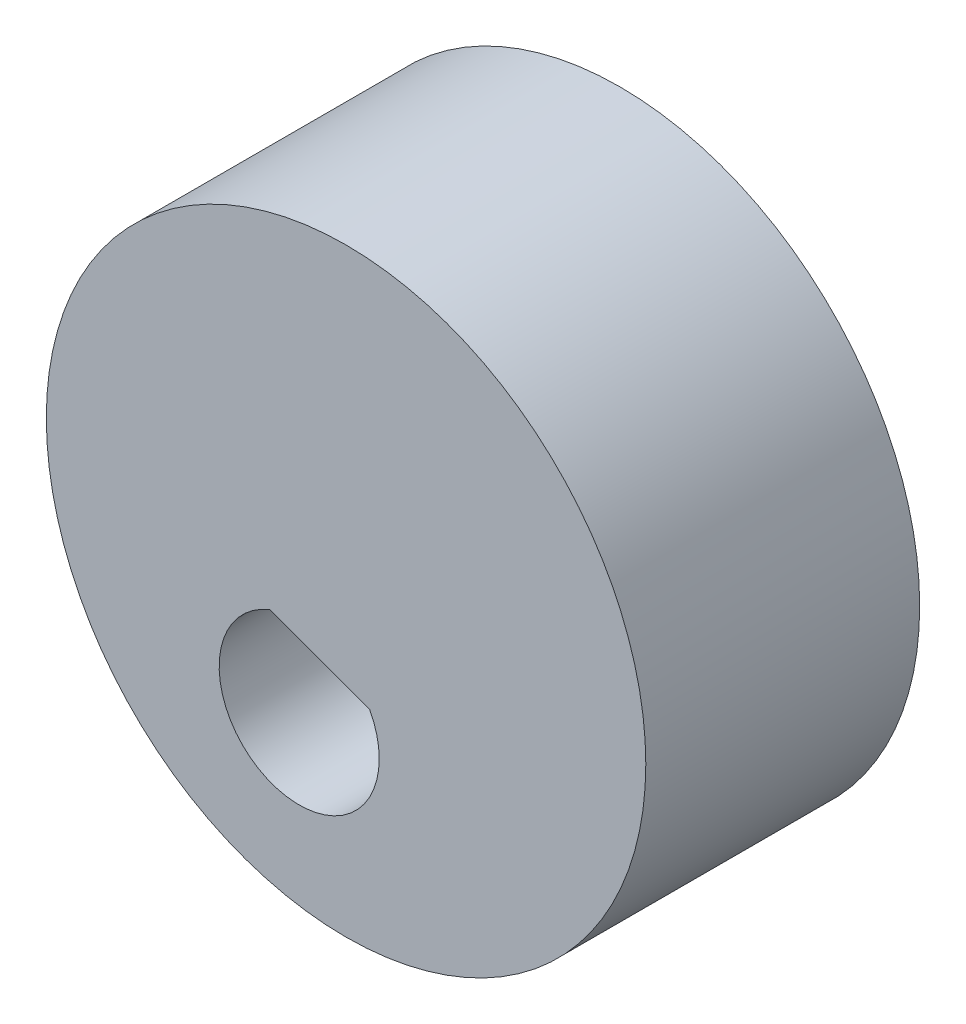
from build123d import *

# Parameters (mm, degrees)
SKETCH2_R           = 9.85
BOSS_EXTRUDE1_DEPTH = 9


with BuildPart() as part:
    # Sketch2 → Boss-Extrude1 (new body)
    with BuildSketch(Plane.XY.offset(-65.766846416)):
        with Locations((-18.602199674, -32.896108502)):
            Circle(SKETCH2_R)
        with BuildLine():
            Line((-21.095188771, -34.673155506), (-17.825677236, -35.879096765))
            ThreePointArc((-17.825677236, -35.879096765), (-21.05228654, -39.591911385), (-21.095188771, -34.673155506))
        make_face(mode=Mode.SUBTRACT)
    extrude(amount=BOSS_EXTRUDE1_DEPTH)


solid = part.part
